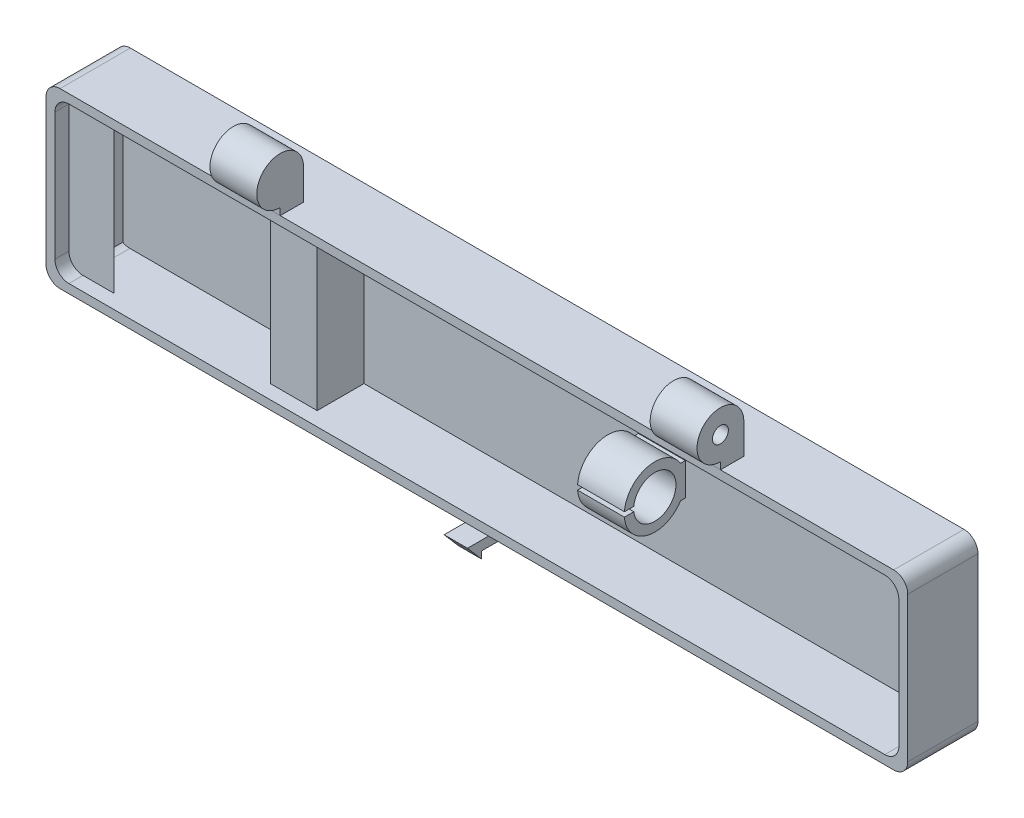
from build123d import *

# Parameters (mm, degrees)
CROQUIS1_W                   = 184
CROQUIS1_H                   = 37
SALIENTE_EXTRUIR1_DEPTH      = 15
CROQUIS3_W                   = 180.2
CROQUIS3_H                   = 33.2
CORTAR_EXTRUIR2_DEPTH        = 13
SALIENTE_EXTRUIR2_START      = -40
SALIENTE_EXTRUIR2_DEPTH      = 10
CROQUIS5_R                   = 1.7
CORTAR_EXTRUIR3_DEPTH        = 5
REDONDEO1_R                  = 3
SALIENTE_EXTRUIR3_START      = -92
SALIENTE_EXTRUIR3_DEPTH      = 2.5
SALIENTE_EXTRUIR3_DEPTH_BACK = 2.5
SALIENTE_EXTRUIR4_START      = 63.6
SALIENTE_EXTRUIR4_DEPTH      = 5
SALIENTE_EXTRUIR4_DEPTH_BACK = 5
SALIENTE_EXTRUIR5_DEPTH      = 33.2


with BuildPart() as part:
    # Croquis1 → Saliente-Extruir1 (new body)
    with BuildSketch(Plane.XY):
        with Locations((-92, 18.5)):
            Rectangle(CROQUIS1_W, CROQUIS1_H)
    extrude(amount=SALIENTE_EXTRUIR1_DEPTH)

    # Croquis3 → Cortar-Extruir2 (cut)
    with BuildSketch(Plane.XY.offset(15)):
        with Locations((-92, 18.5)):
            Rectangle(CROQUIS3_W, CROQUIS3_H)
    extrude(amount=-CORTAR_EXTRUIR2_DEPTH, mode=Mode.SUBTRACT)

    # Redondeo1
    redondeo1_edges = [part.edges().sort_by_distance(p)[0] for p in [
        (-1.9, 1.9, 8.5),
        (-182.1, 1.9, 8.5),
        (-182.1, 35.1, 8.5),
        (-1.9, 35.1, 8.5),
        (0, 0, 7.5),
        (-184, 0, 7.5),
        (-184, 37, 7.5),
        (0, 37, 7.5),
    ]]
    fillet(redondeo1_edges, radius=REDONDEO1_R)

    # Croquis6 → Saliente-Extruir3 (add, two sides)
    with BuildSketch(Plane.ZY.offset(184).offset(SALIENTE_EXTRUIR3_START)) as saliente_extruir3_sk:
        Polygon((15, 0), (19.5, 0), (16.5, -3.5), (16.5, -2), (10, -2), (7.666666667, 0), align=None)
    extrude(amount=SALIENTE_EXTRUIR3_DEPTH)
    extrude(saliente_extruir3_sk.sketch, amount=-SALIENTE_EXTRUIR3_DEPTH_BACK)

    # Croquis7 → Saliente-Extruir4 (add, two sides)
    with BuildSketch(Plane.ZY.offset(1.9).offset(SALIENTE_EXTRUIR4_START)) as saliente_extruir4_sk:
        with BuildLine():
            Line((3, 21.966876226), (2, 21.966876226))
            Line((2, 21.966876226), (2, 18.5))
            Line((2, 18.5), (2, 15.033123774))
            Line((2, 15.033123774), (3, 15.033123774))
            ThreePointArc((3, 15.033123774), (10.072006407, 12.180662475), (15, 18))
            Line((15, 18), (13, 18))
            ThreePointArc((13, 18), (3.991479265, 18.5), (13, 19))
            Line((13, 19), (15, 19))
            ThreePointArc((15, 19), (10.072006407, 24.819337525), (3, 21.966876226))
        make_face()
    extrude(amount=SALIENTE_EXTRUIR4_DEPTH)
    extrude(saliente_extruir4_sk.sketch, amount=-SALIENTE_EXTRUIR4_DEPTH_BACK)

    # Croquis8 → Saliente-Extruir5 (add)
    with BuildSketch(Plane.XZ.offset(-35.1)):
        Polygon((-129.1, 2), (-129.1, 12), (-139.1, 12), (-131, 3.9), (-131, 2), align=None)
        Polygon((-182.5, 12), (-172.5, 12), (-180.6, 3.9), (-180.6, 2), (-182.5, 2), align=None)
    extrude(amount=SALIENTE_EXTRUIR5_DEPTH)


with BuildPart() as body_2:
    # Croquis4 → Saliente-Extruir2 (new body)
    with BuildSketch(Plane.ZY.offset(184).offset(SALIENTE_EXTRUIR2_START)):
        with BuildLine():
            Line((15, 38.5), (15, 37))
            Line((15, 37), (10, 37))
            Line((10, 37), (10, 43.5))
            ThreePointArc((10, 43.5), (18.535533906, 47.035533906), (15, 38.5))
        make_face()
    extrude(amount=-SALIENTE_EXTRUIR2_DEPTH)

    # Croquis5 → Cortar-Extruir3 (cut)
    with BuildSketch(Plane.ZY.offset(144)):
        with Locations((15, 43.5)):
            Circle(CROQUIS5_R)
    extrude(amount=-CORTAR_EXTRUIR3_DEPTH, mode=Mode.SUBTRACT)


with BuildPart() as body_3:
    # Simetría1: mirrored copy
    add(body_2.part.mirror(Plane.ZY.offset(92)))


solid = Compound([part.part, body_2.part, body_3.part])
